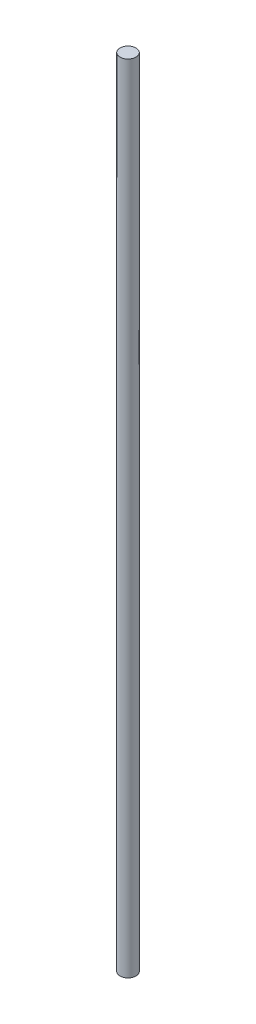
from build123d import *

# Parameters (mm, degrees)
SKETCH1_R           = 2.54
BOSS_EXTRUDE1_DEPTH = 253.238


with BuildPart() as part:
    # Sketch1 → Boss-Extrude1 (new body)
    with BuildSketch(Plane(origin=(0, 0, 0), x_dir=(1, 0, 0), z_dir=(0, 1, 0))):
        Circle(SKETCH1_R)
    extrude(amount=BOSS_EXTRUDE1_DEPTH)


solid = part.part
